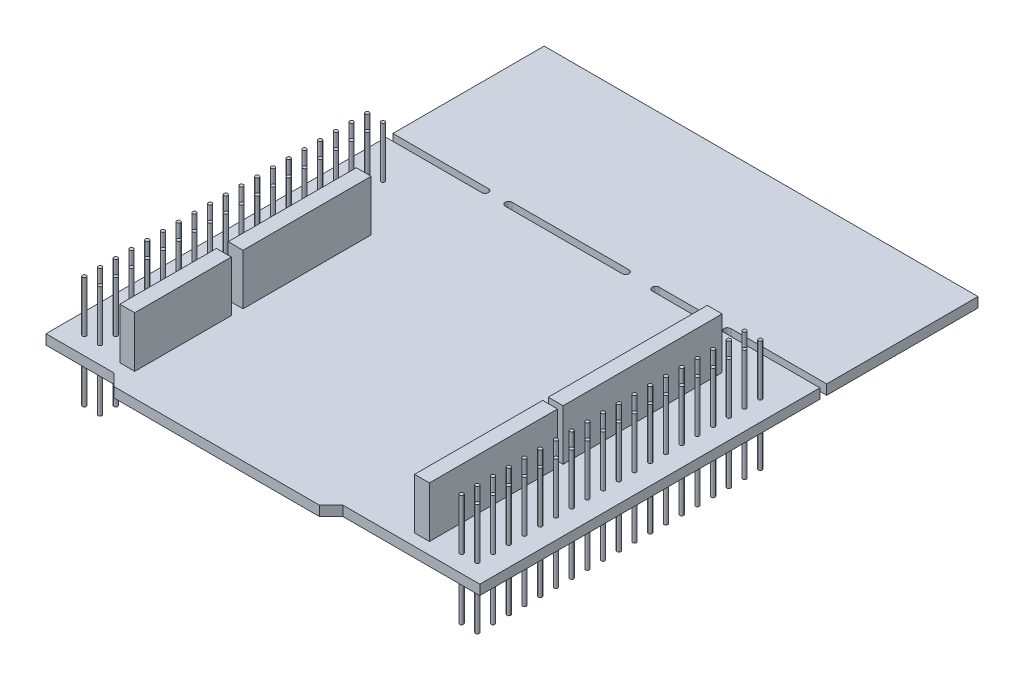
from build123d import *

# Parameters (mm, degrees)
BOSS_EXTRUDE1_DEPTH                        = 1.6
SKETCH2_R                                  = 0.3
BOSS_EXTRUDE2_DEPTH                        = 8.25
LPATTERN1_COUNT                            = 19
LPATTERN1_PITCH                            = 2.54
MIRROR1_COPY_1_SKETCH_R                    = 0.3
MIRROR1_COPY_1_DEPTH                       = 8.25
MIRROR1_COPY_2_SKETCH_R                    = 0.3
MIRROR1_COPY_2_DEPTH                       = 8.25
MIRROR1_COPY_3_SKETCH_R                    = 0.3
MIRROR1_COPY_3_DEPTH                       = 8.25
MIRROR1_COPY_4_SKETCH_R                    = 0.3
MIRROR1_COPY_4_DEPTH                       = 8.25
MIRROR1_COPY_5_SKETCH_R                    = 0.3
MIRROR1_COPY_5_DEPTH                       = 8.25
MIRROR1_COPY_6_SKETCH_R                    = 0.3
MIRROR1_COPY_6_DEPTH                       = 8.25
MIRROR1_COPY_7_SKETCH_R                    = 0.3
MIRROR1_COPY_7_DEPTH                       = 8.25
MIRROR1_COPY_8_SKETCH_R                    = 0.3
MIRROR1_COPY_8_DEPTH                       = 8.25
MIRROR1_COPY_9_SKETCH_R                    = 0.3
MIRROR1_COPY_9_DEPTH                       = 8.25
MIRROR1_COPY_10_SKETCH_R                   = 0.3
MIRROR1_COPY_10_DEPTH                      = 8.25
MIRROR1_COPY_11_SKETCH_R                   = 0.3
MIRROR1_COPY_11_DEPTH                      = 8.25
MIRROR1_COPY_12_SKETCH_R                   = 0.3
MIRROR1_COPY_12_DEPTH                      = 8.25
MIRROR1_COPY_13_SKETCH_R                   = 0.3
MIRROR1_COPY_13_DEPTH                      = 8.25
MIRROR1_COPY_14_SKETCH_R                   = 0.3
MIRROR1_COPY_14_DEPTH                      = 8.25
MIRROR1_COPY_15_SKETCH_R                   = 0.3
MIRROR1_COPY_15_DEPTH                      = 8.25
MIRROR1_COPY_16_SKETCH_R                   = 0.3
MIRROR1_COPY_16_DEPTH                      = 8.25
MIRROR1_COPY_17_SKETCH_R                   = 0.3
MIRROR1_COPY_17_DEPTH                      = 8.25
MIRROR1_COPY_18_SKETCH_R                   = 0.3
MIRROR1_COPY_18_DEPTH                      = 8.25
MIRROR1_AT_THE_SECOND_PLANE_COPY_1_SKETC_R = 0.3
MIRROR1_AT_THE_SECOND_PLANE_COPY_1_DEPTH   = 8.25
MIRROR1_AT_THE_SECOND_PLANE_COPY_2_SKETC_R = 0.3
MIRROR1_AT_THE_SECOND_PLANE_COPY_2_DEPTH   = 8.25
MIRROR1_AT_THE_SECOND_PLANE_COPY_3_SKETC_R = 0.3
MIRROR1_AT_THE_SECOND_PLANE_COPY_3_DEPTH   = 8.25
MIRROR1_AT_THE_SECOND_PLANE_COPY_4_SKETC_R = 0.3
MIRROR1_AT_THE_SECOND_PLANE_COPY_4_DEPTH   = 8.25
MIRROR1_AT_THE_SECOND_PLANE_COPY_5_SKETC_R = 0.3
MIRROR1_AT_THE_SECOND_PLANE_COPY_5_DEPTH   = 8.25
MIRROR1_AT_THE_SECOND_PLANE_COPY_6_SKETC_R = 0.3
MIRROR1_AT_THE_SECOND_PLANE_COPY_6_DEPTH   = 8.25
MIRROR1_AT_THE_SECOND_PLANE_COPY_7_SKETC_R = 0.3
MIRROR1_AT_THE_SECOND_PLANE_COPY_7_DEPTH   = 8.25
MIRROR1_AT_THE_SECOND_PLANE_COPY_8_SKETC_R = 0.3
MIRROR1_AT_THE_SECOND_PLANE_COPY_8_DEPTH   = 8.25
MIRROR1_AT_THE_SECOND_PLANE_COPY_9_SKETC_R = 0.3
MIRROR1_AT_THE_SECOND_PLANE_COPY_9_DEPTH   = 8.25
MIRROR1_AT_THE_SECOND_PLANE_COPY_10_SKET_R = 0.3
MIRROR1_AT_THE_SECOND_PLANE_COPY_10_DEPTH  = 8.25
MIRROR1_AT_THE_SECOND_PLANE_COPY_11_SKET_R = 0.3
MIRROR1_AT_THE_SECOND_PLANE_COPY_11_DEPTH  = 8.25
MIRROR1_AT_THE_SECOND_PLANE_COPY_12_SKET_R = 0.3
MIRROR1_AT_THE_SECOND_PLANE_COPY_12_DEPTH  = 8.25
MIRROR1_AT_THE_SECOND_PLANE_COPY_13_SKET_R = 0.3
MIRROR1_AT_THE_SECOND_PLANE_COPY_13_DEPTH  = 8.25
MIRROR1_AT_THE_SECOND_PLANE_COPY_14_SKET_R = 0.3
MIRROR1_AT_THE_SECOND_PLANE_COPY_14_DEPTH  = 8.25
MIRROR1_AT_THE_SECOND_PLANE_COPY_15_SKET_R = 0.3
MIRROR1_AT_THE_SECOND_PLANE_COPY_15_DEPTH  = 8.25
MIRROR1_AT_THE_SECOND_PLANE_COPY_16_SKET_R = 0.3
MIRROR1_AT_THE_SECOND_PLANE_COPY_16_DEPTH  = 8.25
MIRROR1_AT_THE_SECOND_PLANE_COPY_17_SKET_R = 0.3
MIRROR1_AT_THE_SECOND_PLANE_COPY_17_DEPTH  = 8.25
MIRROR1_AT_THE_SECOND_PLANE_COPY_18_SKET_R = 0.3
MIRROR1_AT_THE_SECOND_PLANE_COPY_18_DEPTH  = 8.25
MIRROR1_AT_THE_SECOND_PLANE_COPY_19_SKET_R = 0.3
MIRROR1_AT_THE_SECOND_PLANE_COPY_19_DEPTH  = 8.25
MIRROR1_AT_THE_SECOND_PLANE_COPY_20_SKET_R = 0.3
MIRROR1_AT_THE_SECOND_PLANE_COPY_20_DEPTH  = 8.25
MIRROR1_AT_THE_SECOND_PLANE_COPY_21_SKET_R = 0.3
MIRROR1_AT_THE_SECOND_PLANE_COPY_21_DEPTH  = 8.25
MIRROR1_AT_THE_SECOND_PLANE_COPY_22_SKET_R = 0.3
MIRROR1_AT_THE_SECOND_PLANE_COPY_22_DEPTH  = 8.25
MIRROR1_AT_THE_SECOND_PLANE_COPY_23_SKET_R = 0.3
MIRROR1_AT_THE_SECOND_PLANE_COPY_23_DEPTH  = 8.25
MIRROR1_AT_THE_SECOND_PLANE_COPY_24_SKET_R = 0.3
MIRROR1_AT_THE_SECOND_PLANE_COPY_24_DEPTH  = 8.25
MIRROR1_AT_THE_SECOND_PLANE_COPY_25_SKET_R = 0.3
MIRROR1_AT_THE_SECOND_PLANE_COPY_25_DEPTH  = 8.25
MIRROR1_AT_THE_SECOND_PLANE_COPY_26_SKET_R = 0.3
MIRROR1_AT_THE_SECOND_PLANE_COPY_26_DEPTH  = 8.25
MIRROR1_AT_THE_SECOND_PLANE_COPY_27_SKET_R = 0.3
MIRROR1_AT_THE_SECOND_PLANE_COPY_27_DEPTH  = 8.25
MIRROR1_AT_THE_SECOND_PLANE_COPY_28_SKET_R = 0.3
MIRROR1_AT_THE_SECOND_PLANE_COPY_28_DEPTH  = 8.25
MIRROR1_AT_THE_SECOND_PLANE_COPY_29_SKET_R = 0.3
MIRROR1_AT_THE_SECOND_PLANE_COPY_29_DEPTH  = 8.25
MIRROR1_AT_THE_SECOND_PLANE_COPY_30_SKET_R = 0.3
MIRROR1_AT_THE_SECOND_PLANE_COPY_30_DEPTH  = 8.25
MIRROR1_AT_THE_SECOND_PLANE_COPY_31_SKET_R = 0.3
MIRROR1_AT_THE_SECOND_PLANE_COPY_31_DEPTH  = 8.25
MIRROR1_AT_THE_SECOND_PLANE_COPY_32_SKET_R = 0.3
MIRROR1_AT_THE_SECOND_PLANE_COPY_32_DEPTH  = 8.25
MIRROR1_AT_THE_SECOND_PLANE_COPY_33_SKET_R = 0.3
MIRROR1_AT_THE_SECOND_PLANE_COPY_33_DEPTH  = 8.25
MIRROR1_AT_THE_SECOND_PLANE_COPY_34_SKET_R = 0.3
MIRROR1_AT_THE_SECOND_PLANE_COPY_34_DEPTH  = 8.25
MIRROR1_AT_THE_SECOND_PLANE_COPY_35_SKET_R = 0.3
MIRROR1_AT_THE_SECOND_PLANE_COPY_35_DEPTH  = 8.25
MIRROR1_AT_THE_SECOND_PLANE_COPY_36_SKET_R = 0.3
MIRROR1_AT_THE_SECOND_PLANE_COPY_36_DEPTH  = 8.25
MIRROR1_AT_THE_SECOND_PLANE_COPY_37_SKET_R = 0.3
MIRROR1_AT_THE_SECOND_PLANE_COPY_37_DEPTH  = 8.25
SKETCH3_W                                  = 2.4
SKETCH3_H                                  = 15.6
SKETCH3_H_2                                = 20.7
SKETCH3_H_3                                = 25.7
BOSS_EXTRUDE3_DEPTH                        = 8.2


with BuildPart() as part:
    # Sketch1 → Boss-Extrude1 (new body)
    with BuildSketch(Plane(origin=(0, 0, 0), x_dir=(1, 0, 0), z_dir=(0, 1, 0))):
        with BuildLine():
            Line((-35.05, -40.25), (-24.05, -40.25))
            Line((-24.05, -40.25), (-22.15, -42.15))
            Line((-22.15, -42.15), (11.05, -42.15))
            Line((11.05, -42.15), (12.95, -40.25))
            Line((12.95, -40.25), (35.05, -40.25))
            Line((35.05, -40.25), (35.05, 14.7))
            Line((35.05, 14.7), (19.55, 14.7))
            ThreePointArc((19.55, 14.7), (19, 15.25), (19.55, 15.8))
            Line((19.55, 15.8), (35.05, 15.8))
            Line((35.05, 15.8), (35.05, 40.25))
            Line((35.05, 40.25), (-35.05, 40.25))
            Line((-35.05, 40.25), (-35.05, 15.8))
            Line((-35.05, 15.8), (-19.6, 15.8))
            ThreePointArc((-19.6, 15.8), (-19.05, 15.25), (-19.6, 14.7))
            Line((-19.6, 14.7), (-35.05, 14.7))
            Line((-35.05, 14.7), (-35.05, -40.25))
        make_face()
        with BuildLine():
            ThreePointArc((-15.8, 14.7), (-16.35, 15.25), (-15.8, 15.8))
            Line((-15.8, 15.8), (3.1, 15.8))
            ThreePointArc((3.1, 15.8), (3.65, 15.25), (3.1, 14.7))
            Line((3.1, 14.7), (-15.8, 14.7))
        make_face(mode=Mode.SUBTRACT)
        with BuildLine():
            ThreePointArc((7.95, 14.7), (7.4, 15.25), (7.95, 15.8))
            Line((7.95, 15.8), (15.15, 15.8))
            ThreePointArc((15.15, 15.8), (15.7, 15.25), (15.15, 14.7))
            Line((15.15, 14.7), (7.95, 14.7))
        make_face(mode=Mode.SUBTRACT)
    extrude(amount=BOSS_EXTRUDE1_DEPTH)

    # Sketch2 → Boss-Extrude2 (add)
    with BuildSketch(Plane(origin=(0, 1.6, 0), x_dir=(1, 0, 0), z_dir=(0, 1, 0))):
        with Locations((-31.75, -37.35)):
            Circle(SKETCH2_R)
        with Locations((-29.21, -37.35)):
            Circle(SKETCH2_R)
    boss_extrude2 = extrude(amount=BOSS_EXTRUDE2_DEPTH)

    # LPattern1: Boss-Extrude2 ×19
    with Locations(*[(0, 0, -i * LPATTERN1_PITCH) for i in range(1, LPATTERN1_COUNT)]):
        add(boss_extrude2)

    # Mirror1: Boss-Extrude2 across plane
    add(boss_extrude2.mirror(Plane.ZX.offset(0.8)))

    # Mirror1 copy 1 sketch → Mirror1 copy 1 (add)
    with BuildSketch(Plane(origin=(0, 0, -2.54), x_dir=(1, 0, 0), z_dir=(0, -1, 0))):
        with Locations((-31.75, 37.35)):
            Circle(MIRROR1_COPY_1_SKETCH_R)
        with Locations((-29.21, 37.35)):
            Circle(MIRROR1_COPY_1_SKETCH_R)
    extrude(amount=MIRROR1_COPY_1_DEPTH)

    # Mirror1 copy 2 sketch → Mirror1 copy 2 (add)
    with BuildSketch(Plane(origin=(0, 0, -5.08), x_dir=(1, 0, 0), z_dir=(0, -1, 0))):
        with Locations((-31.75, 37.35)):
            Circle(MIRROR1_COPY_2_SKETCH_R)
        with Locations((-29.21, 37.35)):
            Circle(MIRROR1_COPY_2_SKETCH_R)
    extrude(amount=MIRROR1_COPY_2_DEPTH)

    # Mirror1 copy 3 sketch → Mirror1 copy 3 (add)
    with BuildSketch(Plane(origin=(0, 0, -7.62), x_dir=(1, 0, 0), z_dir=(0, -1, 0))):
        with Locations((-31.75, 37.35)):
            Circle(MIRROR1_COPY_3_SKETCH_R)
        with Locations((-29.21, 37.35)):
            Circle(MIRROR1_COPY_3_SKETCH_R)
    extrude(amount=MIRROR1_COPY_3_DEPTH)

    # Mirror1 copy 4 sketch → Mirror1 copy 4 (add)
    with BuildSketch(Plane(origin=(0, 0, -10.16), x_dir=(1, 0, 0), z_dir=(0, -1, 0))):
        with Locations((-31.75, 37.35)):
            Circle(MIRROR1_COPY_4_SKETCH_R)
        with Locations((-29.21, 37.35)):
            Circle(MIRROR1_COPY_4_SKETCH_R)
    extrude(amount=MIRROR1_COPY_4_DEPTH)

    # Mirror1 copy 5 sketch → Mirror1 copy 5 (add)
    with BuildSketch(Plane(origin=(0, 0, -12.7), x_dir=(1, 0, 0), z_dir=(0, -1, 0))):
        with Locations((-31.75, 37.35)):
            Circle(MIRROR1_COPY_5_SKETCH_R)
        with Locations((-29.21, 37.35)):
            Circle(MIRROR1_COPY_5_SKETCH_R)
    extrude(amount=MIRROR1_COPY_5_DEPTH)

    # Mirror1 copy 6 sketch → Mirror1 copy 6 (add)
    with BuildSketch(Plane(origin=(0, 0, -15.24), x_dir=(1, 0, 0), z_dir=(0, -1, 0))):
        with Locations((-31.75, 37.35)):
            Circle(MIRROR1_COPY_6_SKETCH_R)
        with Locations((-29.21, 37.35)):
            Circle(MIRROR1_COPY_6_SKETCH_R)
    extrude(amount=MIRROR1_COPY_6_DEPTH)

    # Mirror1 copy 7 sketch → Mirror1 copy 7 (add)
    with BuildSketch(Plane(origin=(0, 0, -17.78), x_dir=(1, 0, 0), z_dir=(0, -1, 0))):
        with Locations((-31.75, 37.35)):
            Circle(MIRROR1_COPY_7_SKETCH_R)
        with Locations((-29.21, 37.35)):
            Circle(MIRROR1_COPY_7_SKETCH_R)
    extrude(amount=MIRROR1_COPY_7_DEPTH)

    # Mirror1 copy 8 sketch → Mirror1 copy 8 (add)
    with BuildSketch(Plane(origin=(0, 0, -20.32), x_dir=(1, 0, 0), z_dir=(0, -1, 0))):
        with Locations((-31.75, 37.35)):
            Circle(MIRROR1_COPY_8_SKETCH_R)
        with Locations((-29.21, 37.35)):
            Circle(MIRROR1_COPY_8_SKETCH_R)
    extrude(amount=MIRROR1_COPY_8_DEPTH)

    # Mirror1 copy 9 sketch → Mirror1 copy 9 (add)
    with BuildSketch(Plane(origin=(0, 0, -22.86), x_dir=(1, 0, 0), z_dir=(0, -1, 0))):
        with Locations((-31.75, 37.35)):
            Circle(MIRROR1_COPY_9_SKETCH_R)
        with Locations((-29.21, 37.35)):
            Circle(MIRROR1_COPY_9_SKETCH_R)
    extrude(amount=MIRROR1_COPY_9_DEPTH)

    # Mirror1 copy 10 sketch → Mirror1 copy 10 (add)
    with BuildSketch(Plane(origin=(0, 0, -25.4), x_dir=(1, 0, 0), z_dir=(0, -1, 0))):
        with Locations((-31.75, 37.35)):
            Circle(MIRROR1_COPY_10_SKETCH_R)
        with Locations((-29.21, 37.35)):
            Circle(MIRROR1_COPY_10_SKETCH_R)
    extrude(amount=MIRROR1_COPY_10_DEPTH)

    # Mirror1 copy 11 sketch → Mirror1 copy 11 (add)
    with BuildSketch(Plane(origin=(0, 0, -27.94), x_dir=(1, 0, 0), z_dir=(0, -1, 0))):
        with Locations((-31.75, 37.35)):
            Circle(MIRROR1_COPY_11_SKETCH_R)
        with Locations((-29.21, 37.35)):
            Circle(MIRROR1_COPY_11_SKETCH_R)
    extrude(amount=MIRROR1_COPY_11_DEPTH)

    # Mirror1 copy 12 sketch → Mirror1 copy 12 (add)
    with BuildSketch(Plane(origin=(0, 0, -30.48), x_dir=(1, 0, 0), z_dir=(0, -1, 0))):
        with Locations((-31.75, 37.35)):
            Circle(MIRROR1_COPY_12_SKETCH_R)
        with Locations((-29.21, 37.35)):
            Circle(MIRROR1_COPY_12_SKETCH_R)
    extrude(amount=MIRROR1_COPY_12_DEPTH)

    # Mirror1 copy 13 sketch → Mirror1 copy 13 (add)
    with BuildSketch(Plane(origin=(0, 0, -33.02), x_dir=(1, 0, 0), z_dir=(0, -1, 0))):
        with Locations((-31.75, 37.35)):
            Circle(MIRROR1_COPY_13_SKETCH_R)
        with Locations((-29.21, 37.35)):
            Circle(MIRROR1_COPY_13_SKETCH_R)
    extrude(amount=MIRROR1_COPY_13_DEPTH)

    # Mirror1 copy 14 sketch → Mirror1 copy 14 (add)
    with BuildSketch(Plane(origin=(0, 0, -35.56), x_dir=(1, 0, 0), z_dir=(0, -1, 0))):
        with Locations((-31.75, 37.35)):
            Circle(MIRROR1_COPY_14_SKETCH_R)
        with Locations((-29.21, 37.35)):
            Circle(MIRROR1_COPY_14_SKETCH_R)
    extrude(amount=MIRROR1_COPY_14_DEPTH)

    # Mirror1 copy 15 sketch → Mirror1 copy 15 (add)
    with BuildSketch(Plane(origin=(0, 0, -38.1), x_dir=(1, 0, 0), z_dir=(0, -1, 0))):
        with Locations((-31.75, 37.35)):
            Circle(MIRROR1_COPY_15_SKETCH_R)
        with Locations((-29.21, 37.35)):
            Circle(MIRROR1_COPY_15_SKETCH_R)
    extrude(amount=MIRROR1_COPY_15_DEPTH)

    # Mirror1 copy 16 sketch → Mirror1 copy 16 (add)
    with BuildSketch(Plane(origin=(0, 0, -40.64), x_dir=(1, 0, 0), z_dir=(0, -1, 0))):
        with Locations((-31.75, 37.35)):
            Circle(MIRROR1_COPY_16_SKETCH_R)
        with Locations((-29.21, 37.35)):
            Circle(MIRROR1_COPY_16_SKETCH_R)
    extrude(amount=MIRROR1_COPY_16_DEPTH)

    # Mirror1 copy 17 sketch → Mirror1 copy 17 (add)
    with BuildSketch(Plane(origin=(0, 0, -43.18), x_dir=(1, 0, 0), z_dir=(0, -1, 0))):
        with Locations((-31.75, 37.35)):
            Circle(MIRROR1_COPY_17_SKETCH_R)
        with Locations((-29.21, 37.35)):
            Circle(MIRROR1_COPY_17_SKETCH_R)
    extrude(amount=MIRROR1_COPY_17_DEPTH)

    # Mirror1 copy 18 sketch → Mirror1 copy 18 (add)
    with BuildSketch(Plane(origin=(0, 0, -45.72), x_dir=(1, 0, 0), z_dir=(0, -1, 0))):
        with Locations((-31.75, 37.35)):
            Circle(MIRROR1_COPY_18_SKETCH_R)
        with Locations((-29.21, 37.35)):
            Circle(MIRROR1_COPY_18_SKETCH_R)
    extrude(amount=MIRROR1_COPY_18_DEPTH)

    # Mirror1 at the second plane: Boss-Extrude2 across plane
    add(boss_extrude2.mirror(Plane(origin=(0, 0, 0), x_dir=(0, 0, 1), z_dir=(1, 0, 0))))

    # Mirror1 at the second plane copy 1 sketc → Mirror1 at the second plane copy 1 (add)
    with BuildSketch(Plane(origin=(0, 1.6, -2.54), x_dir=(-1, 0, 0), z_dir=(0, 1, 0))):
        with Locations((-31.75, 37.35)):
            Circle(MIRROR1_AT_THE_SECOND_PLANE_COPY_1_SKETC_R)
        with Locations((-29.21, 37.35)):
            Circle(MIRROR1_AT_THE_SECOND_PLANE_COPY_1_SKETC_R)
    extrude(amount=MIRROR1_AT_THE_SECOND_PLANE_COPY_1_DEPTH)

    # Mirror1 at the second plane copy 2 sketc → Mirror1 at the second plane copy 2 (add)
    with BuildSketch(Plane(origin=(0, 1.6, -5.08), x_dir=(-1, 0, 0), z_dir=(0, 1, 0))):
        with Locations((-31.75, 37.35)):
            Circle(MIRROR1_AT_THE_SECOND_PLANE_COPY_2_SKETC_R)
        with Locations((-29.21, 37.35)):
            Circle(MIRROR1_AT_THE_SECOND_PLANE_COPY_2_SKETC_R)
    extrude(amount=MIRROR1_AT_THE_SECOND_PLANE_COPY_2_DEPTH)

    # Mirror1 at the second plane copy 3 sketc → Mirror1 at the second plane copy 3 (add)
    with BuildSketch(Plane(origin=(0, 1.6, -7.62), x_dir=(-1, 0, 0), z_dir=(0, 1, 0))):
        with Locations((-31.75, 37.35)):
            Circle(MIRROR1_AT_THE_SECOND_PLANE_COPY_3_SKETC_R)
        with Locations((-29.21, 37.35)):
            Circle(MIRROR1_AT_THE_SECOND_PLANE_COPY_3_SKETC_R)
    extrude(amount=MIRROR1_AT_THE_SECOND_PLANE_COPY_3_DEPTH)

    # Mirror1 at the second plane copy 4 sketc → Mirror1 at the second plane copy 4 (add)
    with BuildSketch(Plane(origin=(0, 1.6, -10.16), x_dir=(-1, 0, 0), z_dir=(0, 1, 0))):
        with Locations((-31.75, 37.35)):
            Circle(MIRROR1_AT_THE_SECOND_PLANE_COPY_4_SKETC_R)
        with Locations((-29.21, 37.35)):
            Circle(MIRROR1_AT_THE_SECOND_PLANE_COPY_4_SKETC_R)
    extrude(amount=MIRROR1_AT_THE_SECOND_PLANE_COPY_4_DEPTH)

    # Mirror1 at the second plane copy 5 sketc → Mirror1 at the second plane copy 5 (add)
    with BuildSketch(Plane(origin=(0, 1.6, -12.7), x_dir=(-1, 0, 0), z_dir=(0, 1, 0))):
        with Locations((-31.75, 37.35)):
            Circle(MIRROR1_AT_THE_SECOND_PLANE_COPY_5_SKETC_R)
        with Locations((-29.21, 37.35)):
            Circle(MIRROR1_AT_THE_SECOND_PLANE_COPY_5_SKETC_R)
    extrude(amount=MIRROR1_AT_THE_SECOND_PLANE_COPY_5_DEPTH)

    # Mirror1 at the second plane copy 6 sketc → Mirror1 at the second plane copy 6 (add)
    with BuildSketch(Plane(origin=(0, 1.6, -15.24), x_dir=(-1, 0, 0), z_dir=(0, 1, 0))):
        with Locations((-31.75, 37.35)):
            Circle(MIRROR1_AT_THE_SECOND_PLANE_COPY_6_SKETC_R)
        with Locations((-29.21, 37.35)):
            Circle(MIRROR1_AT_THE_SECOND_PLANE_COPY_6_SKETC_R)
    extrude(amount=MIRROR1_AT_THE_SECOND_PLANE_COPY_6_DEPTH)

    # Mirror1 at the second plane copy 7 sketc → Mirror1 at the second plane copy 7 (add)
    with BuildSketch(Plane(origin=(0, 1.6, -17.78), x_dir=(-1, 0, 0), z_dir=(0, 1, 0))):
        with Locations((-31.75, 37.35)):
            Circle(MIRROR1_AT_THE_SECOND_PLANE_COPY_7_SKETC_R)
        with Locations((-29.21, 37.35)):
            Circle(MIRROR1_AT_THE_SECOND_PLANE_COPY_7_SKETC_R)
    extrude(amount=MIRROR1_AT_THE_SECOND_PLANE_COPY_7_DEPTH)

    # Mirror1 at the second plane copy 8 sketc → Mirror1 at the second plane copy 8 (add)
    with BuildSketch(Plane(origin=(0, 1.6, -20.32), x_dir=(-1, 0, 0), z_dir=(0, 1, 0))):
        with Locations((-31.75, 37.35)):
            Circle(MIRROR1_AT_THE_SECOND_PLANE_COPY_8_SKETC_R)
        with Locations((-29.21, 37.35)):
            Circle(MIRROR1_AT_THE_SECOND_PLANE_COPY_8_SKETC_R)
    extrude(amount=MIRROR1_AT_THE_SECOND_PLANE_COPY_8_DEPTH)

    # Mirror1 at the second plane copy 9 sketc → Mirror1 at the second plane copy 9 (add)
    with BuildSketch(Plane(origin=(0, 1.6, -22.86), x_dir=(-1, 0, 0), z_dir=(0, 1, 0))):
        with Locations((-31.75, 37.35)):
            Circle(MIRROR1_AT_THE_SECOND_PLANE_COPY_9_SKETC_R)
        with Locations((-29.21, 37.35)):
            Circle(MIRROR1_AT_THE_SECOND_PLANE_COPY_9_SKETC_R)
    extrude(amount=MIRROR1_AT_THE_SECOND_PLANE_COPY_9_DEPTH)

    # Mirror1 at the second plane copy 10 sket → Mirror1 at the second plane copy 10 (add)
    with BuildSketch(Plane(origin=(0, 1.6, -25.4), x_dir=(-1, 0, 0), z_dir=(0, 1, 0))):
        with Locations((-31.75, 37.35)):
            Circle(MIRROR1_AT_THE_SECOND_PLANE_COPY_10_SKET_R)
        with Locations((-29.21, 37.35)):
            Circle(MIRROR1_AT_THE_SECOND_PLANE_COPY_10_SKET_R)
    extrude(amount=MIRROR1_AT_THE_SECOND_PLANE_COPY_10_DEPTH)

    # Mirror1 at the second plane copy 11 sket → Mirror1 at the second plane copy 11 (add)
    with BuildSketch(Plane(origin=(0, 1.6, -27.94), x_dir=(-1, 0, 0), z_dir=(0, 1, 0))):
        with Locations((-31.75, 37.35)):
            Circle(MIRROR1_AT_THE_SECOND_PLANE_COPY_11_SKET_R)
        with Locations((-29.21, 37.35)):
            Circle(MIRROR1_AT_THE_SECOND_PLANE_COPY_11_SKET_R)
    extrude(amount=MIRROR1_AT_THE_SECOND_PLANE_COPY_11_DEPTH)

    # Mirror1 at the second plane copy 12 sket → Mirror1 at the second plane copy 12 (add)
    with BuildSketch(Plane(origin=(0, 1.6, -30.48), x_dir=(-1, 0, 0), z_dir=(0, 1, 0))):
        with Locations((-31.75, 37.35)):
            Circle(MIRROR1_AT_THE_SECOND_PLANE_COPY_12_SKET_R)
        with Locations((-29.21, 37.35)):
            Circle(MIRROR1_AT_THE_SECOND_PLANE_COPY_12_SKET_R)
    extrude(amount=MIRROR1_AT_THE_SECOND_PLANE_COPY_12_DEPTH)

    # Mirror1 at the second plane copy 13 sket → Mirror1 at the second plane copy 13 (add)
    with BuildSketch(Plane(origin=(0, 1.6, -33.02), x_dir=(-1, 0, 0), z_dir=(0, 1, 0))):
        with Locations((-31.75, 37.35)):
            Circle(MIRROR1_AT_THE_SECOND_PLANE_COPY_13_SKET_R)
        with Locations((-29.21, 37.35)):
            Circle(MIRROR1_AT_THE_SECOND_PLANE_COPY_13_SKET_R)
    extrude(amount=MIRROR1_AT_THE_SECOND_PLANE_COPY_13_DEPTH)

    # Mirror1 at the second plane copy 14 sket → Mirror1 at the second plane copy 14 (add)
    with BuildSketch(Plane(origin=(0, 1.6, -35.56), x_dir=(-1, 0, 0), z_dir=(0, 1, 0))):
        with Locations((-31.75, 37.35)):
            Circle(MIRROR1_AT_THE_SECOND_PLANE_COPY_14_SKET_R)
        with Locations((-29.21, 37.35)):
            Circle(MIRROR1_AT_THE_SECOND_PLANE_COPY_14_SKET_R)
    extrude(amount=MIRROR1_AT_THE_SECOND_PLANE_COPY_14_DEPTH)

    # Mirror1 at the second plane copy 15 sket → Mirror1 at the second plane copy 15 (add)
    with BuildSketch(Plane(origin=(0, 1.6, -38.1), x_dir=(-1, 0, 0), z_dir=(0, 1, 0))):
        with Locations((-31.75, 37.35)):
            Circle(MIRROR1_AT_THE_SECOND_PLANE_COPY_15_SKET_R)
        with Locations((-29.21, 37.35)):
            Circle(MIRROR1_AT_THE_SECOND_PLANE_COPY_15_SKET_R)
    extrude(amount=MIRROR1_AT_THE_SECOND_PLANE_COPY_15_DEPTH)

    # Mirror1 at the second plane copy 16 sket → Mirror1 at the second plane copy 16 (add)
    with BuildSketch(Plane(origin=(0, 1.6, -40.64), x_dir=(-1, 0, 0), z_dir=(0, 1, 0))):
        with Locations((-31.75, 37.35)):
            Circle(MIRROR1_AT_THE_SECOND_PLANE_COPY_16_SKET_R)
        with Locations((-29.21, 37.35)):
            Circle(MIRROR1_AT_THE_SECOND_PLANE_COPY_16_SKET_R)
    extrude(amount=MIRROR1_AT_THE_SECOND_PLANE_COPY_16_DEPTH)

    # Mirror1 at the second plane copy 17 sket → Mirror1 at the second plane copy 17 (add)
    with BuildSketch(Plane(origin=(0, 1.6, -43.18), x_dir=(-1, 0, 0), z_dir=(0, 1, 0))):
        with Locations((-31.75, 37.35)):
            Circle(MIRROR1_AT_THE_SECOND_PLANE_COPY_17_SKET_R)
        with Locations((-29.21, 37.35)):
            Circle(MIRROR1_AT_THE_SECOND_PLANE_COPY_17_SKET_R)
    extrude(amount=MIRROR1_AT_THE_SECOND_PLANE_COPY_17_DEPTH)

    # Mirror1 at the second plane copy 18 sket → Mirror1 at the second plane copy 18 (add)
    with BuildSketch(Plane(origin=(0, 1.6, -45.72), x_dir=(-1, 0, 0), z_dir=(0, 1, 0))):
        with Locations((-31.75, 37.35)):
            Circle(MIRROR1_AT_THE_SECOND_PLANE_COPY_18_SKET_R)
        with Locations((-29.21, 37.35)):
            Circle(MIRROR1_AT_THE_SECOND_PLANE_COPY_18_SKET_R)
    extrude(amount=MIRROR1_AT_THE_SECOND_PLANE_COPY_18_DEPTH)

    # Mirror1 at the second plane copy 19 sket → Mirror1 at the second plane copy 19 (add)
    with BuildSketch(Plane(origin=(0, 0, 0), x_dir=(-1, 0, 0), z_dir=(0, -1, 0))):
        with Locations((-31.75, -37.35)):
            Circle(MIRROR1_AT_THE_SECOND_PLANE_COPY_19_SKET_R)
        with Locations((-29.21, -37.35)):
            Circle(MIRROR1_AT_THE_SECOND_PLANE_COPY_19_SKET_R)
    extrude(amount=MIRROR1_AT_THE_SECOND_PLANE_COPY_19_DEPTH)

    # Mirror1 at the second plane copy 20 sket → Mirror1 at the second plane copy 20 (add)
    with BuildSketch(Plane(origin=(0, 0, -2.54), x_dir=(-1, 0, 0), z_dir=(0, -1, 0))):
        with Locations((-31.75, -37.35)):
            Circle(MIRROR1_AT_THE_SECOND_PLANE_COPY_20_SKET_R)
        with Locations((-29.21, -37.35)):
            Circle(MIRROR1_AT_THE_SECOND_PLANE_COPY_20_SKET_R)
    extrude(amount=MIRROR1_AT_THE_SECOND_PLANE_COPY_20_DEPTH)

    # Mirror1 at the second plane copy 21 sket → Mirror1 at the second plane copy 21 (add)
    with BuildSketch(Plane(origin=(0, 0, -5.08), x_dir=(-1, 0, 0), z_dir=(0, -1, 0))):
        with Locations((-31.75, -37.35)):
            Circle(MIRROR1_AT_THE_SECOND_PLANE_COPY_21_SKET_R)
        with Locations((-29.21, -37.35)):
            Circle(MIRROR1_AT_THE_SECOND_PLANE_COPY_21_SKET_R)
    extrude(amount=MIRROR1_AT_THE_SECOND_PLANE_COPY_21_DEPTH)

    # Mirror1 at the second plane copy 22 sket → Mirror1 at the second plane copy 22 (add)
    with BuildSketch(Plane(origin=(0, 0, -7.62), x_dir=(-1, 0, 0), z_dir=(0, -1, 0))):
        with Locations((-31.75, -37.35)):
            Circle(MIRROR1_AT_THE_SECOND_PLANE_COPY_22_SKET_R)
        with Locations((-29.21, -37.35)):
            Circle(MIRROR1_AT_THE_SECOND_PLANE_COPY_22_SKET_R)
    extrude(amount=MIRROR1_AT_THE_SECOND_PLANE_COPY_22_DEPTH)

    # Mirror1 at the second plane copy 23 sket → Mirror1 at the second plane copy 23 (add)
    with BuildSketch(Plane(origin=(0, 0, -10.16), x_dir=(-1, 0, 0), z_dir=(0, -1, 0))):
        with Locations((-31.75, -37.35)):
            Circle(MIRROR1_AT_THE_SECOND_PLANE_COPY_23_SKET_R)
        with Locations((-29.21, -37.35)):
            Circle(MIRROR1_AT_THE_SECOND_PLANE_COPY_23_SKET_R)
    extrude(amount=MIRROR1_AT_THE_SECOND_PLANE_COPY_23_DEPTH)

    # Mirror1 at the second plane copy 24 sket → Mirror1 at the second plane copy 24 (add)
    with BuildSketch(Plane(origin=(0, 0, -12.7), x_dir=(-1, 0, 0), z_dir=(0, -1, 0))):
        with Locations((-31.75, -37.35)):
            Circle(MIRROR1_AT_THE_SECOND_PLANE_COPY_24_SKET_R)
        with Locations((-29.21, -37.35)):
            Circle(MIRROR1_AT_THE_SECOND_PLANE_COPY_24_SKET_R)
    extrude(amount=MIRROR1_AT_THE_SECOND_PLANE_COPY_24_DEPTH)

    # Mirror1 at the second plane copy 25 sket → Mirror1 at the second plane copy 25 (add)
    with BuildSketch(Plane(origin=(0, 0, -15.24), x_dir=(-1, 0, 0), z_dir=(0, -1, 0))):
        with Locations((-31.75, -37.35)):
            Circle(MIRROR1_AT_THE_SECOND_PLANE_COPY_25_SKET_R)
        with Locations((-29.21, -37.35)):
            Circle(MIRROR1_AT_THE_SECOND_PLANE_COPY_25_SKET_R)
    extrude(amount=MIRROR1_AT_THE_SECOND_PLANE_COPY_25_DEPTH)

    # Mirror1 at the second plane copy 26 sket → Mirror1 at the second plane copy 26 (add)
    with BuildSketch(Plane(origin=(0, 0, -17.78), x_dir=(-1, 0, 0), z_dir=(0, -1, 0))):
        with Locations((-31.75, -37.35)):
            Circle(MIRROR1_AT_THE_SECOND_PLANE_COPY_26_SKET_R)
        with Locations((-29.21, -37.35)):
            Circle(MIRROR1_AT_THE_SECOND_PLANE_COPY_26_SKET_R)
    extrude(amount=MIRROR1_AT_THE_SECOND_PLANE_COPY_26_DEPTH)

    # Mirror1 at the second plane copy 27 sket → Mirror1 at the second plane copy 27 (add)
    with BuildSketch(Plane(origin=(0, 0, -20.32), x_dir=(-1, 0, 0), z_dir=(0, -1, 0))):
        with Locations((-31.75, -37.35)):
            Circle(MIRROR1_AT_THE_SECOND_PLANE_COPY_27_SKET_R)
        with Locations((-29.21, -37.35)):
            Circle(MIRROR1_AT_THE_SECOND_PLANE_COPY_27_SKET_R)
    extrude(amount=MIRROR1_AT_THE_SECOND_PLANE_COPY_27_DEPTH)

    # Mirror1 at the second plane copy 28 sket → Mirror1 at the second plane copy 28 (add)
    with BuildSketch(Plane(origin=(0, 0, -22.86), x_dir=(-1, 0, 0), z_dir=(0, -1, 0))):
        with Locations((-31.75, -37.35)):
            Circle(MIRROR1_AT_THE_SECOND_PLANE_COPY_28_SKET_R)
        with Locations((-29.21, -37.35)):
            Circle(MIRROR1_AT_THE_SECOND_PLANE_COPY_28_SKET_R)
    extrude(amount=MIRROR1_AT_THE_SECOND_PLANE_COPY_28_DEPTH)

    # Mirror1 at the second plane copy 29 sket → Mirror1 at the second plane copy 29 (add)
    with BuildSketch(Plane(origin=(0, 0, -25.4), x_dir=(-1, 0, 0), z_dir=(0, -1, 0))):
        with Locations((-31.75, -37.35)):
            Circle(MIRROR1_AT_THE_SECOND_PLANE_COPY_29_SKET_R)
        with Locations((-29.21, -37.35)):
            Circle(MIRROR1_AT_THE_SECOND_PLANE_COPY_29_SKET_R)
    extrude(amount=MIRROR1_AT_THE_SECOND_PLANE_COPY_29_DEPTH)

    # Mirror1 at the second plane copy 30 sket → Mirror1 at the second plane copy 30 (add)
    with BuildSketch(Plane(origin=(0, 0, -27.94), x_dir=(-1, 0, 0), z_dir=(0, -1, 0))):
        with Locations((-31.75, -37.35)):
            Circle(MIRROR1_AT_THE_SECOND_PLANE_COPY_30_SKET_R)
        with Locations((-29.21, -37.35)):
            Circle(MIRROR1_AT_THE_SECOND_PLANE_COPY_30_SKET_R)
    extrude(amount=MIRROR1_AT_THE_SECOND_PLANE_COPY_30_DEPTH)

    # Mirror1 at the second plane copy 31 sket → Mirror1 at the second plane copy 31 (add)
    with BuildSketch(Plane(origin=(0, 0, -30.48), x_dir=(-1, 0, 0), z_dir=(0, -1, 0))):
        with Locations((-31.75, -37.35)):
            Circle(MIRROR1_AT_THE_SECOND_PLANE_COPY_31_SKET_R)
        with Locations((-29.21, -37.35)):
            Circle(MIRROR1_AT_THE_SECOND_PLANE_COPY_31_SKET_R)
    extrude(amount=MIRROR1_AT_THE_SECOND_PLANE_COPY_31_DEPTH)

    # Mirror1 at the second plane copy 32 sket → Mirror1 at the second plane copy 32 (add)
    with BuildSketch(Plane(origin=(0, 0, -33.02), x_dir=(-1, 0, 0), z_dir=(0, -1, 0))):
        with Locations((-31.75, -37.35)):
            Circle(MIRROR1_AT_THE_SECOND_PLANE_COPY_32_SKET_R)
        with Locations((-29.21, -37.35)):
            Circle(MIRROR1_AT_THE_SECOND_PLANE_COPY_32_SKET_R)
    extrude(amount=MIRROR1_AT_THE_SECOND_PLANE_COPY_32_DEPTH)

    # Mirror1 at the second plane copy 33 sket → Mirror1 at the second plane copy 33 (add)
    with BuildSketch(Plane(origin=(0, 0, -35.56), x_dir=(-1, 0, 0), z_dir=(0, -1, 0))):
        with Locations((-31.75, -37.35)):
            Circle(MIRROR1_AT_THE_SECOND_PLANE_COPY_33_SKET_R)
        with Locations((-29.21, -37.35)):
            Circle(MIRROR1_AT_THE_SECOND_PLANE_COPY_33_SKET_R)
    extrude(amount=MIRROR1_AT_THE_SECOND_PLANE_COPY_33_DEPTH)

    # Mirror1 at the second plane copy 34 sket → Mirror1 at the second plane copy 34 (add)
    with BuildSketch(Plane(origin=(0, 0, -38.1), x_dir=(-1, 0, 0), z_dir=(0, -1, 0))):
        with Locations((-31.75, -37.35)):
            Circle(MIRROR1_AT_THE_SECOND_PLANE_COPY_34_SKET_R)
        with Locations((-29.21, -37.35)):
            Circle(MIRROR1_AT_THE_SECOND_PLANE_COPY_34_SKET_R)
    extrude(amount=MIRROR1_AT_THE_SECOND_PLANE_COPY_34_DEPTH)

    # Mirror1 at the second plane copy 35 sket → Mirror1 at the second plane copy 35 (add)
    with BuildSketch(Plane(origin=(0, 0, -40.64), x_dir=(-1, 0, 0), z_dir=(0, -1, 0))):
        with Locations((-31.75, -37.35)):
            Circle(MIRROR1_AT_THE_SECOND_PLANE_COPY_35_SKET_R)
        with Locations((-29.21, -37.35)):
            Circle(MIRROR1_AT_THE_SECOND_PLANE_COPY_35_SKET_R)
    extrude(amount=MIRROR1_AT_THE_SECOND_PLANE_COPY_35_DEPTH)

    # Mirror1 at the second plane copy 36 sket → Mirror1 at the second plane copy 36 (add)
    with BuildSketch(Plane(origin=(0, 0, -43.18), x_dir=(-1, 0, 0), z_dir=(0, -1, 0))):
        with Locations((-31.75, -37.35)):
            Circle(MIRROR1_AT_THE_SECOND_PLANE_COPY_36_SKET_R)
        with Locations((-29.21, -37.35)):
            Circle(MIRROR1_AT_THE_SECOND_PLANE_COPY_36_SKET_R)
    extrude(amount=MIRROR1_AT_THE_SECOND_PLANE_COPY_36_DEPTH)

    # Mirror1 at the second plane copy 37 sket → Mirror1 at the second plane copy 37 (add)
    with BuildSketch(Plane(origin=(0, 0, -45.72), x_dir=(-1, 0, 0), z_dir=(0, -1, 0))):
        with Locations((-31.75, -37.35)):
            Circle(MIRROR1_AT_THE_SECOND_PLANE_COPY_37_SKET_R)
        with Locations((-29.21, -37.35)):
            Circle(MIRROR1_AT_THE_SECOND_PLANE_COPY_37_SKET_R)
    extrude(amount=MIRROR1_AT_THE_SECOND_PLANE_COPY_37_DEPTH)

    # Sketch3 → Boss-Extrude3 (add)
    with BuildSketch(Plane(origin=(0, 1.6, 0), x_dir=(1, 0, 0), z_dir=(0, 1, 0))):
        with Locations((-23.81, -30.55)):
            Rectangle(SKETCH3_W, SKETCH3_H)
        with Locations((-23.81, -10.5)):
            Rectangle(SKETCH3_W, SKETCH3_H_2)
        with Locations((23.81, -28)):
            Rectangle(SKETCH3_W, SKETCH3_H_2)
        with Locations((23.81, -3.9)):
            Rectangle(SKETCH3_W, SKETCH3_H_3)
    extrude(amount=BOSS_EXTRUDE3_DEPTH)


solid = part.part
